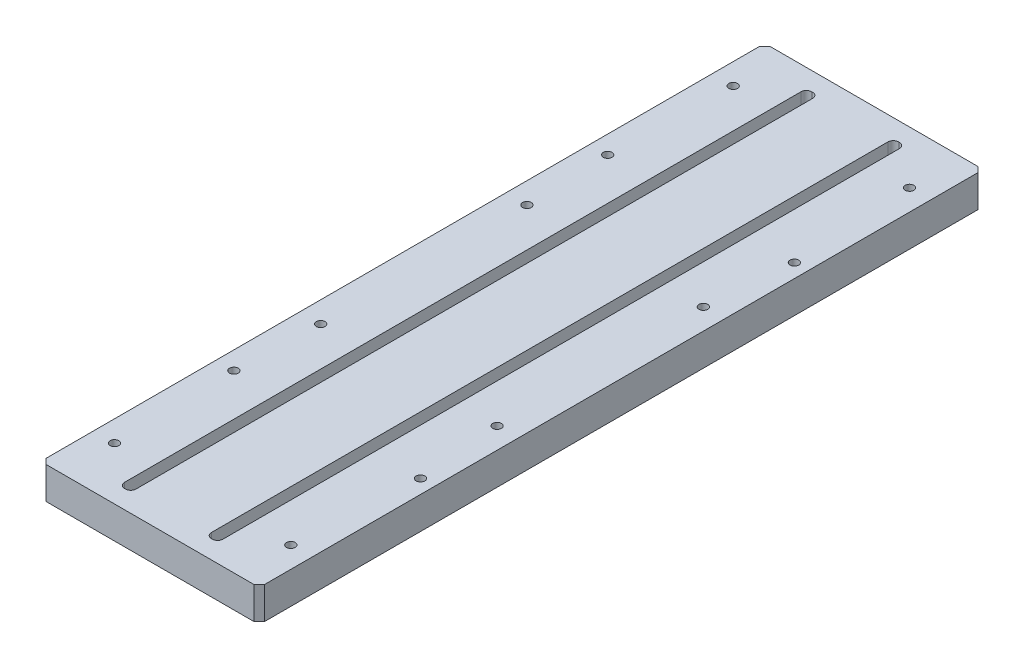
from build123d import *

# Parameters (mm, degrees)
BOSS_EXTRUDE1_DEPTH = 137.5
SKETCH3_W           = 20
SKETCH3_H           = 12.2
BOSS_EXTRUDE2_DEPTH = 2
SKETCH2_W           = 4.4
SKETCH2_H           = 261
CUT_EXTRUDE1_DEPTH  = 13.2
FILLET3_R           = 2
CHAMFER1_SIZE       = 1
SKETCH4_W           = 10.203047284
SKETCH4_H           = 4
CUT_EXTRUDE2_DEPTH  = 2.5
LPATTERN2_COUNT     = 2
LPATTERN2_PITCH     = 33
BOSS_EXTRUDE3_START = -275
SKETCH7_W           = 13
SKETCH7_H           = 12.2
BOSS_EXTRUDE3_DEPTH = 275
SKETCH8_W           = 275
SKETCH8_H           = 12.2
BOSS_EXTRUDE4_DEPTH = 15
M4_TAPPED_HOLE1_D   = 3.3
LPATTERN3_COUNT     = 4
LPATTERN3_PITCH     = 78.333333333
MIRROR5_COPY_1_D    = 3.3
MIRROR5_COPY_2_D    = 3.3
MIRROR5_COPY_3_D    = 3.3
M4_TAPPED_HOLE2_D   = 3.3
FILLET1_R           = 1.5
CHAMFER2_SIZE       = 0.5
CHAMFER4_SIZE       = 2
FILLET4_R           = 1
M4_TAPPED_HOLE3_D   = 3.3


with BuildPart() as part:
    # Sketch1 → Boss-Extrude1 (new body, symmetric)
    with BuildSketch(Plane.XY):
        Polygon((-10, -2.7), (-10, 9.5), (10, 9.5), (10, -2.7), (8, -2.7), (8, 2.5), (4.2, 2.5), (4.2, 0), (-4.2, 0), (-4.2, 2.5), (-8, 2.5), (-8, -2.7), align=None)
    extrude(amount=BOSS_EXTRUDE1_DEPTH, both=True)

    # Sketch3 → Boss-Extrude2 (add)
    with BuildSketch(Plane.XY.offset(137.5)):
        with Locations((0, 3.4)):
            Rectangle(SKETCH3_W, SKETCH3_H)
    boss_extrude2 = extrude(amount=-BOSS_EXTRUDE2_DEPTH)

    # Mirror1: Boss-Extrude2 across plane
    add(boss_extrude2.mirror(Plane.XY))

    # Sketch2 → Cut-Extrude1 (cut, through all)
    with BuildSketch(Plane(origin=(0, 9.5, 0), x_dir=(1, 0, 0), z_dir=(0, 1, 0))):
        Rectangle(SKETCH2_W, SKETCH2_H)
    extrude(amount=-CUT_EXTRUDE1_DEPTH, mode=Mode.SUBTRACT)

    # Fillet3
    fillet3_edges = [part.edges().sort_by_distance(p)[0] for p in [
        (2.2, 4.75, -130.5),
        (2.2, 4.75, 130.5),
        (-2.2, 4.75, 130.5),
        (-2.2, 4.75, -130.5),
    ]]
    fillet(fillet3_edges, radius=FILLET3_R)

    # Chamfer1
    chamfer1_edges = [part.edges().sort_by_distance(p)[0] for p in [
        (-2.2, 0, 0),
        (0, 0, -130.5),
        (2.2, 0, 0),
        (0, 0, 130.5),
        (-1.614213562, 0, -129.914213562),
        (1.614213562, 0, -129.914213562),
        (1.614213562, 0, 129.914213562),
        (-1.614213562, 0, 129.914213562),
    ]]
    chamfer(chamfer1_edges, length=CHAMFER1_SIZE)

    # Sketch4 → Cut-Extrude2 (cut)
    with BuildSketch(Plane.XZ):
        with Locations((-0.901523642, 133.5)):
            Rectangle(SKETCH4_W, SKETCH4_H)
    cut_extrude2 = extrude(amount=-CUT_EXTRUDE2_DEPTH, mode=Mode.SUBTRACT)

    # Mirror2: Cut-Extrude2 across plane
    add(cut_extrude2.mirror(Plane.XY), mode=Mode.SUBTRACT)


with BuildPart() as lpattern2_1:
    # LPattern2: pattern copy
    add(part.part.moved(Location(Vector(1, 0, 0) * (1 * LPATTERN2_PITCH))))


with BuildPart() as part_1:
    add(part.part)

    add(lpattern2_1.part)  # Boss-Extrude3 merges LPattern2_1
    # Sketch7 → Boss-Extrude3 (add)
    with BuildSketch(Plane(origin=(0, 0, -137.5), x_dir=(-1, 0, 0), z_dir=(0, 0, -1)).offset(BOSS_EXTRUDE3_START)):
        with Locations((-16.5, 3.4)):
            Rectangle(SKETCH7_W, SKETCH7_H)
    extrude(amount=BOSS_EXTRUDE3_DEPTH)

    # Sketch8 → Boss-Extrude4 (add)
    with BuildSketch(Plane.ZY.offset(10)):
        with Locations((0, 3.4)):
            Rectangle(SKETCH8_W, SKETCH8_H)
    boss_extrude4 = extrude(amount=BOSS_EXTRUDE4_DEPTH)

    # Mirror4: Boss-Extrude4 across plane
    add(boss_extrude4.mirror(Plane.ZY.offset(-16.5)))

    # M4 Tapped Hole1 (through all)
    with Locations(Plane(origin=(0, 9.5, 0), x_dir=(1, 0, 0), z_dir=(0, 1, 0))):
        with Locations((-17, 117.5)):
            m4_tapped_hole1 = Hole(M4_TAPPED_HOLE1_D / 2)

    # LPattern3: M4 Tapped Hole1 ×4
    with Locations(*[(0, 0, i * LPATTERN3_PITCH) for i in range(1, LPATTERN3_COUNT)]):
        add(m4_tapped_hole1, mode=Mode.SUBTRACT)

    # Mirror5: M4 Tapped Hole1 across plane
    add(m4_tapped_hole1.mirror(Plane.ZY.offset(-16.5)), mode=Mode.SUBTRACT)

    # Mirror5 copy 1 (through all)
    with Locations(Plane(origin=(33, 9.5, 78.333333333), x_dir=(-1, 0, 0), z_dir=(0, 1, 0))):
        with Locations((-17, -117.5)):
            Hole(MIRROR5_COPY_1_D / 2)

    # Mirror5 copy 2 (through all)
    with Locations(Plane(origin=(33, 9.5, 156.666666667), x_dir=(-1, 0, 0), z_dir=(0, 1, 0))):
        with Locations((-17, -117.5)):
            Hole(MIRROR5_COPY_2_D / 2)

    # Mirror5 copy 3 (through all)
    with Locations(Plane(origin=(33, 9.5, 235), x_dir=(-1, 0, 0), z_dir=(0, 1, 0))):
        with Locations((-17, -117.5)):
            Hole(MIRROR5_COPY_3_D / 2)

    # M4 Tapped Hole2 (through all)
    with Locations(Plane(origin=(0, 9.5, 0), x_dir=(1, 0, 0), z_dir=(0, 1, 0))):
        with Locations((52.741079456, -70.992499999), (52.741079456, 71.007500001)):
            Hole(M4_TAPPED_HOLE2_D / 2)

    # Fillet1
    fillet1_edges = [part_1.edges().sort_by_distance(p)[0] for p in [
        (41, -0.1, 135.5),
        (25, -0.1, 135.5),
        (41, -0.1, -135.5),
        (25, -0.1, -135.5),
        (-8, -0.1, 135.5),
        (8, -0.1, 135.5),
        (-8, -0.1, -135.5),
        (8, -0.1, -135.5),
    ]]
    fillet(fillet1_edges, radius=FILLET1_R)

    # Chamfer2
    chamfer2_edges = [part_1.edges().sort_by_distance(p)[0] for p in [
        (33, -2.7, -135.5),
        (41, -2.7, 0),
        (25, -2.7, 0),
        (33, -2.7, 135.5),
        (0, -2.7, -135.5),
        (-8, -2.7, 0),
        (8, -2.7, 0),
        (0, -2.7, 135.5),
        (40.560660172, -2.7, -135.060660172),
        (25.439339828, -2.7, -135.060660172),
        (40.560660172, -2.7, 135.060660172),
        (25.439339828, -2.7, 135.060660172),
        (-7.560660172, -2.7, -135.060660172),
        (7.560660172, -2.7, -135.060660172),
        (7.560660172, -2.7, 135.060660172),
        (-7.560660172, -2.7, 135.060660172),
    ]]
    chamfer(chamfer2_edges, length=CHAMFER2_SIZE)

    # Chamfer4
    chamfer4_edges = [part_1.edges().sort_by_distance(p)[0] for p in [
        (-25, 3.4, -137.5),
        (-25, 3.4, 137.5),
        (58, 3.4, 137.5),
        (58, 3.4, -137.5),
    ]]
    chamfer(chamfer4_edges, length=CHAMFER4_SIZE)

    # Fillet4
    fillet4_edges = [part_1.edges().sort_by_distance(p)[0] for p in [
        (-4.2, 1.25, 131.5),
        (4.2, 1.25, 131.5),
        (-4.2, 1.25, -131.5),
        (4.2, 1.25, -131.5),
        (28.8, 1.25, 131.5),
        (37.2, 1.25, 131.5),
        (28.8, 1.25, -131.5),
        (37.2, 1.25, -131.5),
    ]]
    fillet(fillet4_edges, radius=FILLET4_R)

    # M4 Tapped Hole3 (through all)
    with Locations(Plane(origin=(0, 9.5, 0), x_dir=(1, 0, 0), z_dir=(0, 1, 0))):
        with Locations((-18.158920544, -70.992499999), (-18.158920544, 71.007500001)):
            Hole(M4_TAPPED_HOLE3_D / 2)


solid = part_1.part
